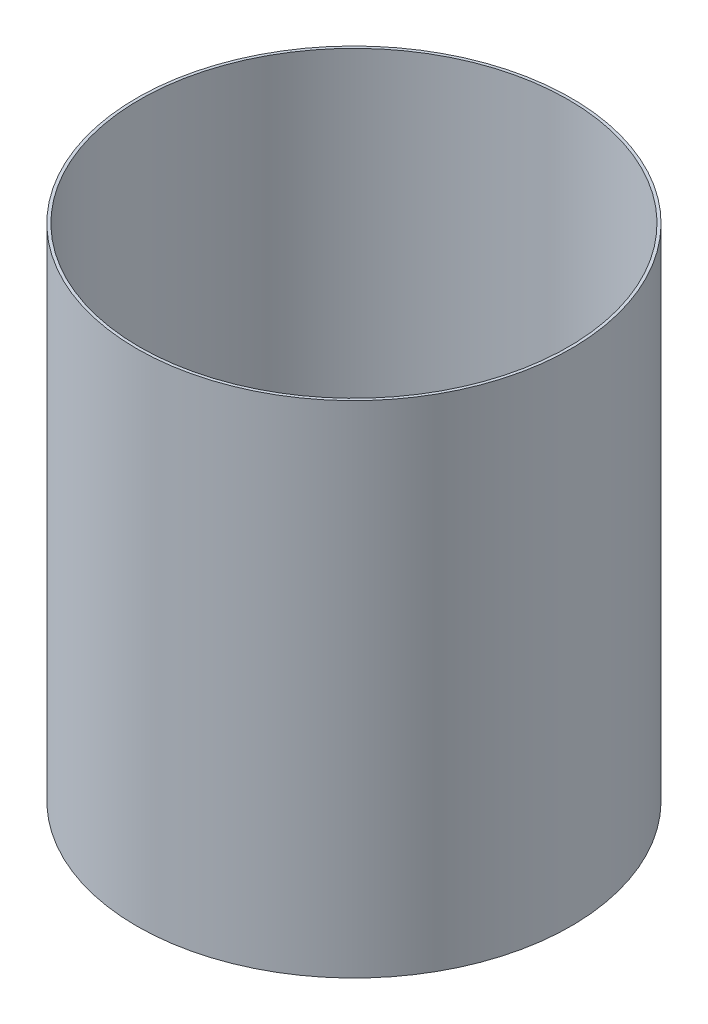
from build123d import *

# Parameters (mm, degrees)
SKETCH2_W = 1.016
SKETCH2_H = 177.8


with BuildPart() as part:
    # Sketch2 → Revolve1 (revolve)
    with BuildSketch(Plane.XY):
        with Locations((76.708, -2.750773558)):
            Rectangle(SKETCH2_W, SKETCH2_H)
    revolve(axis=Axis((0, 55, 0), (0, -1, 0)))


solid = part.part
